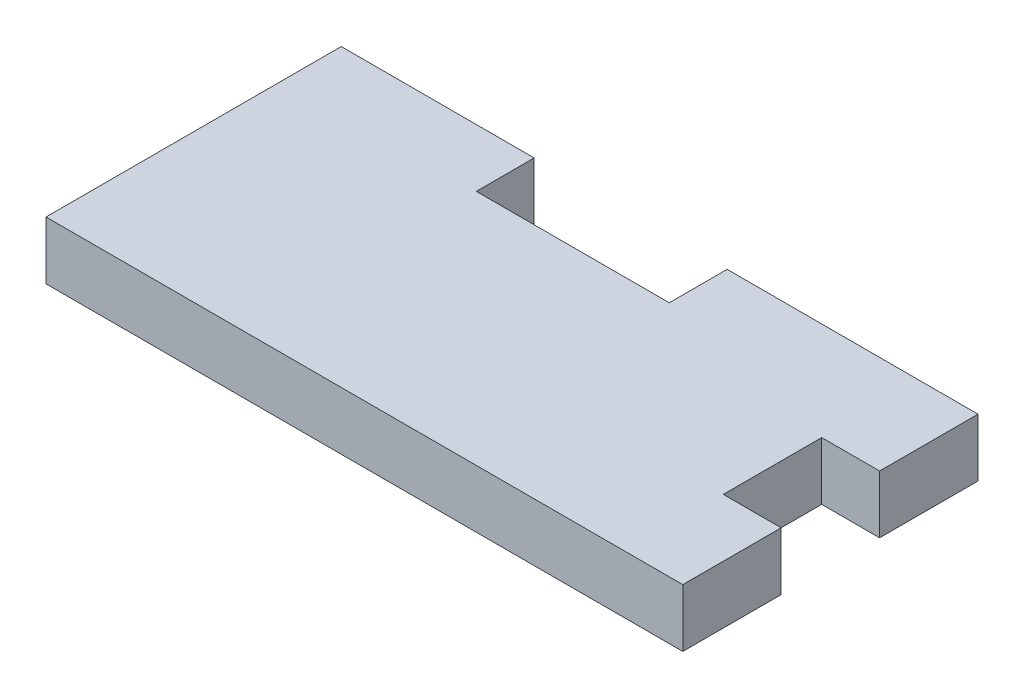
from build123d import *

# Parameters (mm, degrees)
BOSS_EXTRUDE1_DEPTH = 3


with BuildPart() as part:
    # Sketch1 → Boss-Extrude1 (new body)
    with BuildSketch(Plane(origin=(0, 0, 0), x_dir=(1, 0, 0), z_dir=(0, 1, 0))):
        Polygon((0, 0), (30, 0), (33, 0), (33, 5.1), (30, 5.1), (30, 10.2), (33, 10.2), (33, 15.3), (30, 15.3), (20, 15.3), (20, 12.3), (10, 12.3), (10, 15.3), (0, 15.3), align=None)
    extrude(amount=BOSS_EXTRUDE1_DEPTH)


solid = part.part
